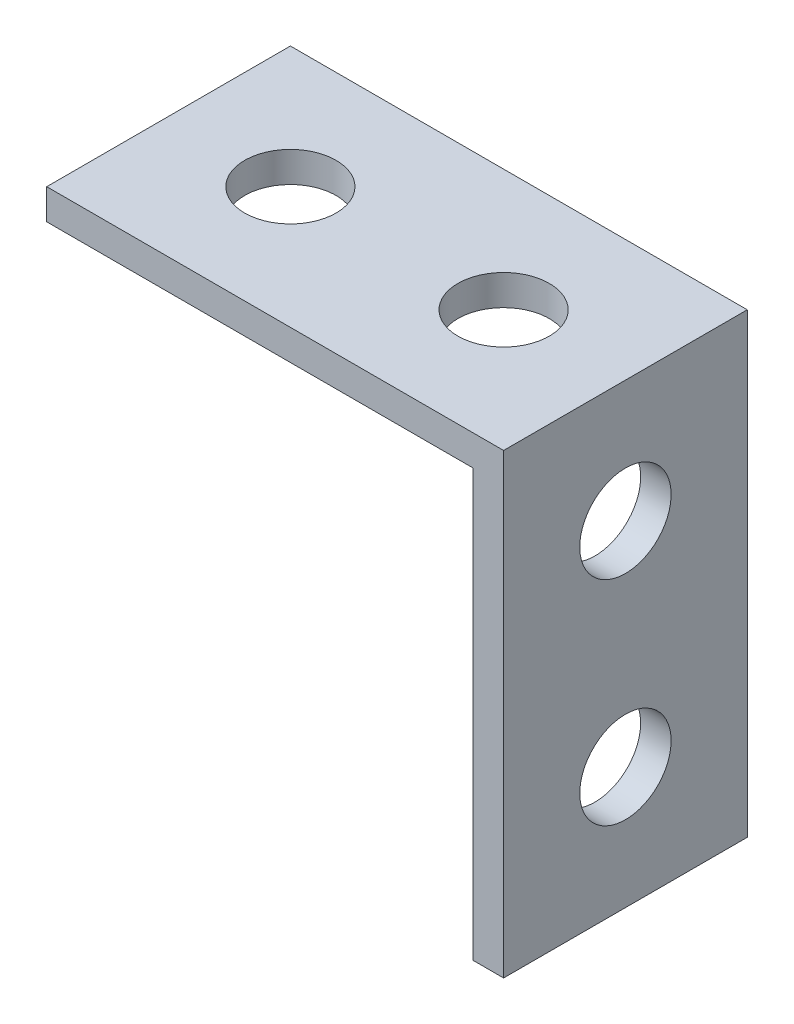
from build123d import *

# Parameters (mm, degrees)
SKETCH1_W           = 15
SKETCH1_H           = 1
SKETCH1_W_2         = 1
SKETCH1_H_2         = 14
BOSS_EXTRUDE1_DEPTH = 8
SKETCH2_R           = 1.5
CUT_EXTRUDE1_DEPTH  = 16
SKETCH3_R           = 1.5
CUT_EXTRUDE2_DEPTH  = 16


with BuildPart() as part:
    # Sketch1 → Boss-Extrude1 (new body)
    with BuildSketch(Plane.XY):
        Rectangle(SKETCH1_W, SKETCH1_H)
        with Locations((7, -7.5)):
            Rectangle(SKETCH1_W_2, SKETCH1_H_2)
    extrude(amount=BOSS_EXTRUDE1_DEPTH)

    # Sketch2 → Cut-Extrude1 (cut, through all)
    with BuildSketch(Plane(origin=(0, 0.5, 0), x_dir=(1, 0, 0), z_dir=(0, 1, 0))):
        with Locations((-3.5, -4)):
            Circle(SKETCH2_R)
        with Locations((3.5, -4)):
            Circle(SKETCH2_R)
    extrude(amount=-CUT_EXTRUDE1_DEPTH, mode=Mode.SUBTRACT)

    # Sketch3 → Cut-Extrude2 (cut, through all)
    with BuildSketch(Plane(origin=(7.5, 0, 0), x_dir=(0, 0, -1), z_dir=(1, 0, 0))):
        with Locations((-4, -3.5)):
            Circle(SKETCH3_R)
        with Locations((-4, -10.5)):
            Circle(SKETCH3_R)
    extrude(amount=-CUT_EXTRUDE2_DEPTH, mode=Mode.SUBTRACT)


solid = part.part
